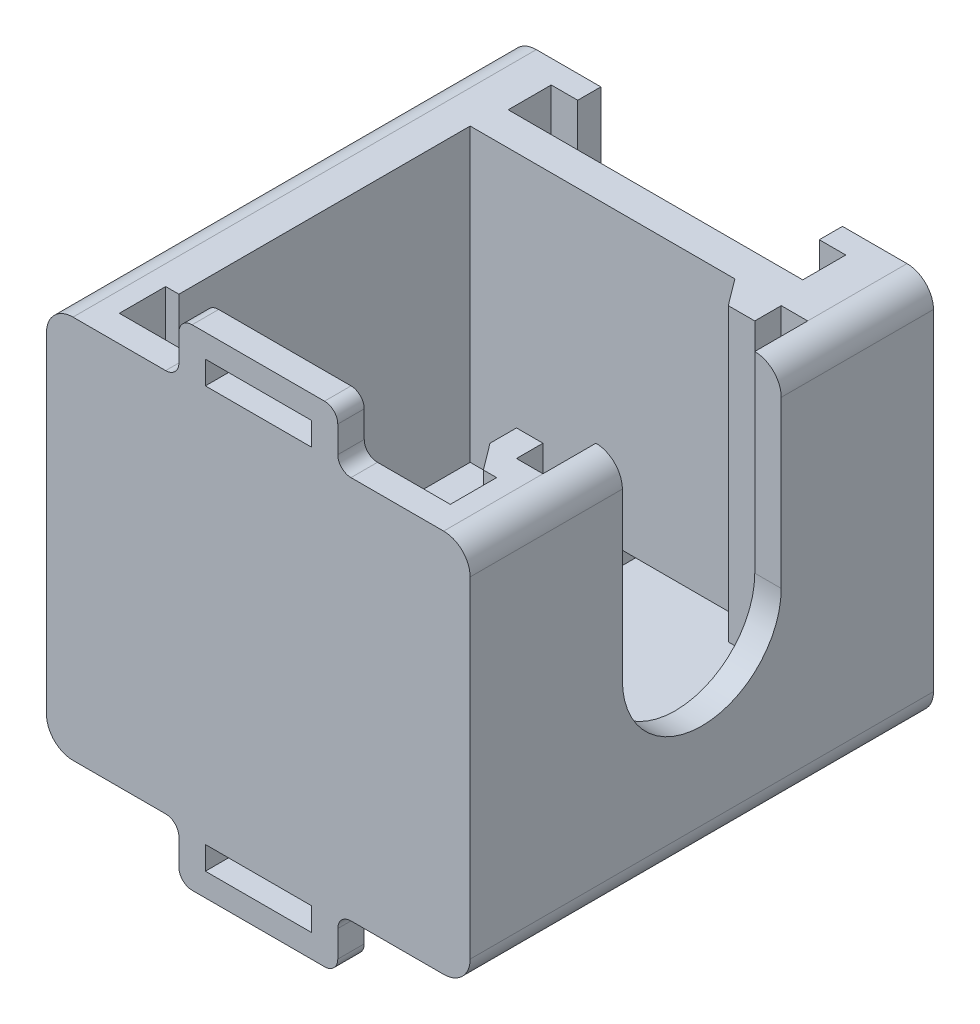
from build123d import *

# Parameters (mm, degrees)
SKETCH1_W                         = 32
SKETCH1_H                         = 29
BOSS_EXTRUDE1_DEPTH               = 35
FILLET1_R                         = 2
SLOT_FOR_COIL_DEPTH               = 1
SLOT_FOR_COIL_DEPTH_BACK          = 30
BOSS_EXTRUDE2_DEPTH               = 7
BOSS_EXTRUDE3_DEPTH               = 1.75
SKETCH5_W                         = 2
SKETCH5_H                         = 7
SLOT_TO_FEED_IN_WIRE_DEPTH        = 33
SLOT_FO_PCB_DEPTH                 = 22
SKETCH7_W                         = 2
SKETCH7_H                         = 33
BOSS_EXTRUDE4_DEPTH               = 0.25
FILLET2_R                         = 6
ROD_MOUNT_SLOT_REACH              = 34
SKETCH14_W                        = 2.5
SKETCH14_H                        = 20
SIDE_CAVITY_FOR_MOUNT_PLATE_DEPTH = 22
SKETCH16_W                        = 2
SKETCH16_H                        = 2
SIDE_STOPS_FOR_MOUNT_PLATE_DEPTH  = 22
BOSS_EXTRUDE6_DEPTH               = 22
SKETCH21_W                        = 12
SKETCH21_H                        = 2
BOSS_EXTRUDE7_DEPTH               = 4
SKETCH23_W                        = 8
SKETCH23_H                        = 1.75
CUT_EXTRUDE7_DEPTH                = 2
FILLET3_R                         = 1
CUT_EXTRUDE8_REACH                = 34
SKETCH26_R                        = 5.25


with BuildPart() as part:
    # Sketch1 → Boss-Extrude1 (new body)
    with BuildSketch(Plane.XY):
        Rectangle(SKETCH1_W, SKETCH1_H)
    extrude(amount=BOSS_EXTRUDE1_DEPTH)

    # Fillet1
    fillet1_edges = [part.edges().sort_by_distance(p)[0] for p in [
        (16, -14.5, 17.5),
        (-16, -14.5, 17.5),
        (-16, 14.5, 17.5),
        (16, 14.5, 17.5),
    ]]
    fillet(fillet1_edges, radius=FILLET1_R)

    # Sketch2 → Slot for Coil (cut, two sides)
    with BuildSketch(Plane.XZ.offset(14.5)) as slot_for_coil_sk:
        Polygon((-9.125, 0), (-9.125, 1.75), (-11.125, 1.75), (-11.125, 5), (11.125, 5), (11.125, 1.75), (9.125, 1.75), (9.125, 0), align=None)
    extrude(amount=SLOT_FOR_COIL_DEPTH, mode=Mode.SUBTRACT)
    extrude(slot_for_coil_sk.sketch, amount=-SLOT_FOR_COIL_DEPTH_BACK, mode=Mode.SUBTRACT)

    # Sketch3 → Boss-Extrude2 (add)
    with BuildSketch(Plane.XZ.offset(14.5)):
        Polygon((-9.125, 0), (-9.125, 1.75), (-11.125, 1.75), (-11.125, 5), (11.125, 5), (11.125, 1.75), (9.125, 1.75), (9.125, 0), align=None)
    extrude(amount=-BOSS_EXTRUDE2_DEPTH)

    # Sketch4 → Boss-Extrude3 (add)
    with BuildSketch(Plane(origin=(0, 0, 1.75), x_dir=(-1, 0, 0), z_dir=(0, 0, -1))):
        with BuildLine():
            Line((-9.125, 7.5), (-9.125, 6.5))
            ThreePointArc((-9.125, 6.5), (-8.875, 7), (-9.125, 7.5))
        make_face()
    boss_extrude3 = extrude(amount=BOSS_EXTRUDE3_DEPTH)

    # Mirror1: Boss-Extrude3 across plane
    add(boss_extrude3.mirror(Plane(origin=(0, 0, 0), x_dir=(0, 0, 1), z_dir=(1, 0, 0))))

    # Sketch5 → slot to feed in wire (cut)
    with BuildSketch(Plane(origin=(0, 0, 0), x_dir=(-1, 0, 0), z_dir=(0, 0, -1))):
        with Locations((0, -11)):
            Rectangle(SKETCH5_W, SKETCH5_H)
    extrude(amount=-SLOT_TO_FEED_IN_WIRE_DEPTH, mode=Mode.SUBTRACT)

    # Sketch6 → slot fo PCB (cut)
    with BuildSketch(Plane(origin=(0, 14.5, 0), x_dir=(1, 0, 0), z_dir=(0, 1, 0))):
        Polygon((11.5, -7.5), (-11.5, -7.5), (-11.5, -29.5), (-12.5, -29.5), (-12.5, -33), (12.5, -33), (12.5, -29.5), (11.5, -29.5), align=None)
    extrude(amount=-SLOT_FO_PCB_DEPTH, mode=Mode.SUBTRACT)

    # Sketch7 → Boss-Extrude4 (add)
    with BuildSketch(Plane.XZ.offset(14.5)):
        with Locations((0, 16.5)):
            Rectangle(SKETCH7_W, SKETCH7_H)
    extrude(amount=-BOSS_EXTRUDE4_DEPTH)

    # Fillet2
    fillet2_edges = [part.edges().sort_by_distance(p)[0] for p in [
        (0, -14.25, 33),
    ]]
    fillet(fillet2_edges, radius=FILLET2_R)

    # Sketch11 → Rod Mount Slot (cut, up to next)
    with BuildSketch(Plane(origin=(16, 0, 44), x_dir=(0, 0, -1), z_dir=(1, 0, 0)), mode=Mode.PRIVATE) as rod_mount_slot_sk1:
        with BuildLine():
            Line((32.5, 25), (32.5, 0))
            ThreePointArc((32.5, 0), (26.5, -6), (20.5, 0))
            Line((20.5, 0), (20.5, 25))
            ThreePointArc((20.5, 25), (26.5, 31), (32.5, 25))
        make_face()
    rod_mount_slot_tool1 = extrude(rod_mount_slot_sk1.sketch, amount=-ROD_MOUNT_SLOT_REACH, mode=Mode.PRIVATE) & part.part
    add(rod_mount_slot_tool1.solids().sort_by_distance((16, 12.5, 17.5))[0], mode=Mode.SUBTRACT)

    # Sketch14 → Side cavity for mount plate (cut)
    with BuildSketch(Plane(origin=(0, 14.5, 0), x_dir=(1, 0, 0), z_dir=(0, 1, 0))):
        with Locations((12.75, -17.5)):
            Rectangle(SKETCH14_W, SKETCH14_H)
    extrude(amount=-SIDE_CAVITY_FOR_MOUNT_PLATE_DEPTH, mode=Mode.SUBTRACT)

    # Sketch16 → Side stops for mount plate (add)
    with BuildSketch(Plane(origin=(0, 14.5, 0), x_dir=(1, 0, 0), z_dir=(0, 1, 0))):
        with Locations((11, -8.5)):
            Rectangle(SKETCH16_W, SKETCH16_H)
        with Locations((11, -26.5)):
            Rectangle(SKETCH16_W, SKETCH16_H)
    extrude(amount=-SIDE_STOPS_FOR_MOUNT_PLATE_DEPTH)

    # Sketch20 → Boss-Extrude6 (add)
    with BuildSketch(Plane(origin=(0, 14.5, 0), x_dir=(1, 0, 0), z_dir=(0, 1, 0))):
        Polygon((11.5, -29.5), (10, -27.5), (11.5, -27.5), align=None)
        Polygon((10, -9.5), (8.5, -7.5), (10, -7.5), align=None)
    extrude(amount=-BOSS_EXTRUDE6_DEPTH)

    # Sketch21 → Boss-Extrude7 (add)
    with BuildSketch(Plane(origin=(0, 14.5, 0), x_dir=(-1, 0, 0), z_dir=(0, 1, 0))):
        with Locations((0, 34)):
            Rectangle(SKETCH21_W, SKETCH21_H)
    boss_extrude7 = extrude(amount=BOSS_EXTRUDE7_DEPTH)

    # Sketch23 → Cut-Extrude7 (cut)
    with BuildSketch(Plane.XY.offset(35)):
        with Locations((0, 15.875)):
            Rectangle(SKETCH23_W, SKETCH23_H)
    cut_extrude7 = extrude(amount=-CUT_EXTRUDE7_DEPTH, mode=Mode.SUBTRACT)

    # Mirror3: Boss-Extrude7, Cut-Extrude7 across plane
    add(boss_extrude7.mirror(Plane.ZX))
    add(cut_extrude7.mirror(Plane.ZX), mode=Mode.SUBTRACT)

    # Fillet3
    fillet3_edges = [part.edges().sort_by_distance(p)[0] for p in [
        (6, 14.5, 34),
        (-6, 14.5, 34),
        (6, 18.5, 34),
        (-6, 18.5, 34),
        (6, -18.5, 34),
        (-6, -18.5, 34),
        (6, -14.5, 34),
        (-6, -14.5, 34),
    ]]
    fillet(fillet3_edges, radius=FILLET3_R)

    # Sketch26 → Cut-Extrude8 (cut, up to next)
    with BuildSketch(Plane(origin=(-16, 0, 0), x_dir=(0, 0, -1), z_dir=(1, 0, 0)), mode=Mode.PRIVATE) as cut_extrude8_sk1:
        with Locations((-23.015, -2.89)):
            Circle(SKETCH26_R)
    cut_extrude8_tool1 = extrude(cut_extrude8_sk1.sketch, amount=CUT_EXTRUDE8_REACH, mode=Mode.PRIVATE) & part.part
    add(cut_extrude8_tool1.solids().sort_by_distance((-16, -2.89, 23.015))[0], mode=Mode.SUBTRACT)


solid = part.part
